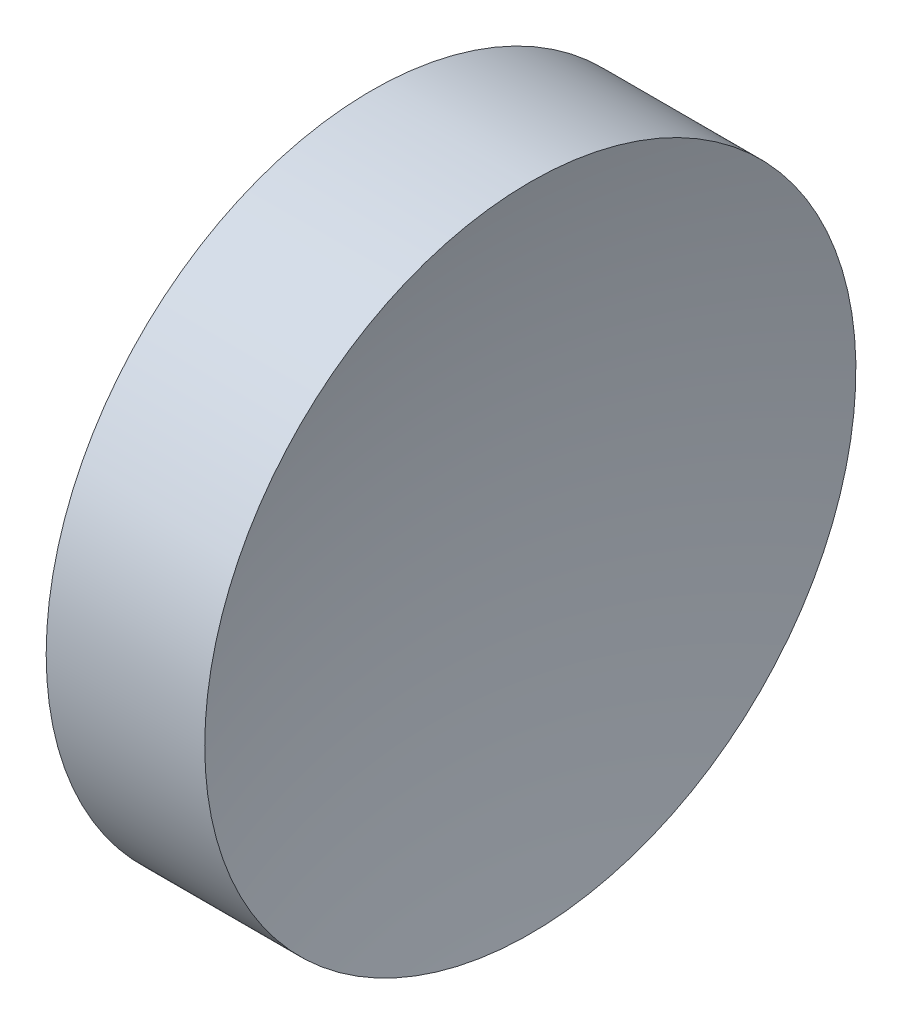
from build123d import *


with BuildPart() as part:
    # 草图1 → 旋转1 (revolve)
    with BuildSketch(Plane.XY):
        with BuildLine():
            Line((230.18531107, 138.756042247), (230.18531107, 163.756042247))
            Line((230.18531107, 163.756042247), (242.360727415, 163.756042247))
            ThreePointArc((242.360727415, 163.756042247), (239.982341443, 151.356471495), (239.18531107, 138.756042247))
            Line((239.18531107, 138.756042247), (230.18531107, 138.756042247))
        make_face()
    revolve(axis=Axis((217.970286004, 138.756042247, 0), (1, 0, 0)))


solid = part.part
